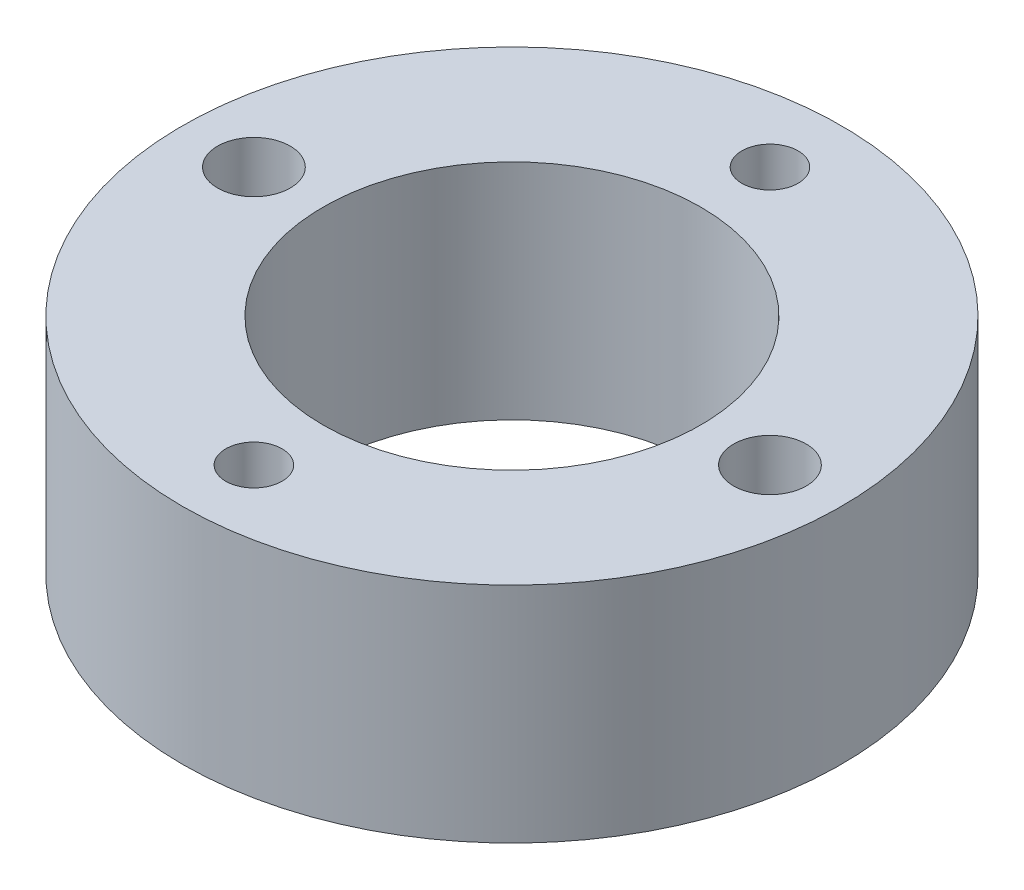
from build123d import *

# Parameters (mm, degrees)
SKETCH1_R           = 14.05
SKETCH1_R_2         = 8.05
SKETCH1_R_3         = 1.55
SKETCH1_R_4         = 1.2
BOSS_EXTRUDE1_DEPTH = 9.525


with BuildPart() as part:
    # Sketch1 → Boss-Extrude1 (new body)
    with BuildSketch(Plane(origin=(0, 0, 0), x_dir=(1, 0, 0), z_dir=(0, 1, 0))):
        Circle(SKETCH1_R)
        Circle(SKETCH1_R_2, mode=Mode.SUBTRACT)
        with Locations((11, 0)):
            Circle(SKETCH1_R_3, mode=Mode.SUBTRACT)
        with Locations((-11, 0)):
            Circle(SKETCH1_R_3, mode=Mode.SUBTRACT)
        with Locations((0, 11)):
            Circle(SKETCH1_R_4, mode=Mode.SUBTRACT)
        with Locations((0, -11)):
            Circle(SKETCH1_R_4, mode=Mode.SUBTRACT)
    extrude(amount=BOSS_EXTRUDE1_DEPTH)


solid = part.part
